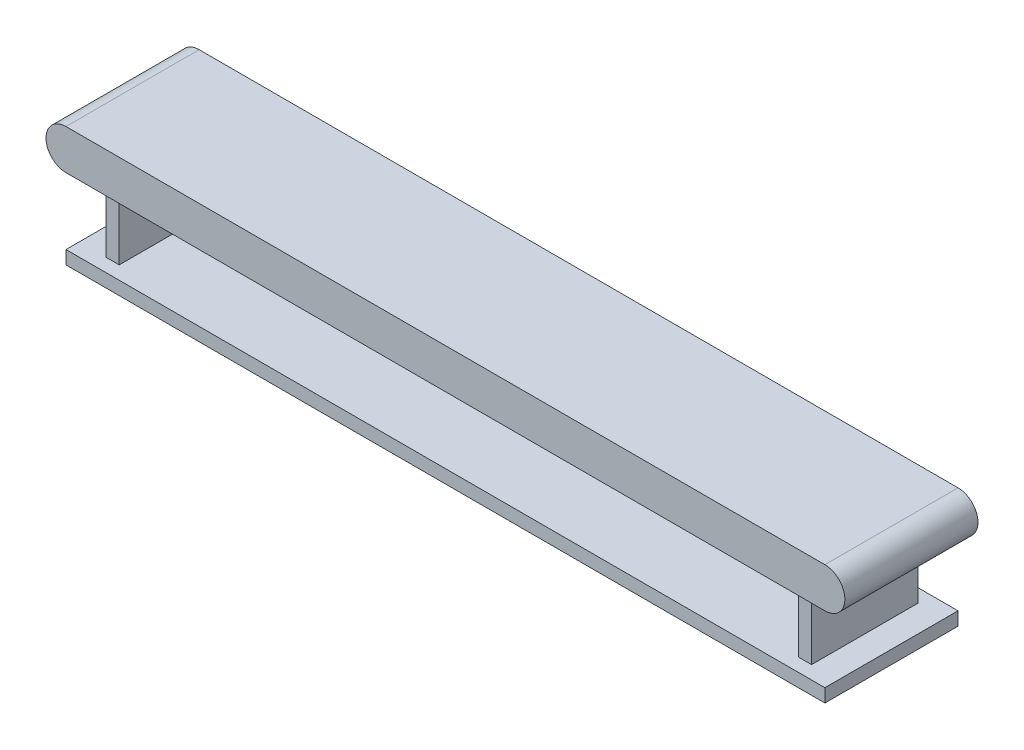
from build123d import *

# Parameters (mm, degrees)
SKETCH1_W           = 6000
SKETCH1_H           = 1000
BOSS_EXTRUDE1_DEPTH = 300
CUT_EXTRUDE1_DEPTH  = 1001
SKETCH5_W           = 100
SKETCH5_H           = 800
BOSS_EXTRUDE2_DEPTH = 500
SKETCH6_W           = 5700
SKETCH6_H           = 1000
BOSS_EXTRUDE3_DEPTH = 100


with BuildPart() as part:
    # Sketch1 → Boss-Extrude1 (new body)
    with BuildSketch(Plane(origin=(0, 0, 0), x_dir=(1, 0, 0), z_dir=(0, 1, 0))):
        Rectangle(SKETCH1_W, SKETCH1_H)
    extrude(amount=BOSS_EXTRUDE1_DEPTH)

    # Sketch4 → Cut-Extrude1 (cut, through all)
    with BuildSketch(Plane.XY.offset(500)):
        with BuildLine():
            Line((3000, 300), (2850, 300))
            ThreePointArc((2850, 300), (2956.066017178, 256.066017178), (3000, 150))
            Line((3000, 150), (3000, 300))
        make_face()
        with BuildLine():
            Line((3000, 0), (3000, 150))
            ThreePointArc((3000, 150), (2956.066017178, 43.933982822), (2850, 0))
            Line((2850, 0), (3000, 0))
        make_face()
        with BuildLine():
            Line((-2850, 300), (-3000, 300))
            Line((-3000, 300), (-3000, 150))
            ThreePointArc((-3000, 150), (-2956.066017178, 256.066017178), (-2850, 300))
        make_face()
        with BuildLine():
            ThreePointArc((-2850, 0), (-2956.066017178, 43.933982822), (-3000, 150))
            Line((-3000, 150), (-3000, 0))
            Line((-3000, 0), (-2850, 0))
        make_face()
    extrude(amount=-CUT_EXTRUDE1_DEPTH, mode=Mode.SUBTRACT)

    # Sketch5 → Boss-Extrude2 (add)
    with BuildSketch(Plane(origin=(0, 0, 0), x_dir=(-1, 0, 0), z_dir=(0, -1, 0))):
        with Locations((2600, 0)):
            Rectangle(SKETCH5_W, SKETCH5_H)
        with Locations((-2600, 0)):
            Rectangle(SKETCH5_W, SKETCH5_H)
    extrude(amount=BOSS_EXTRUDE2_DEPTH)

    # Sketch6 → Boss-Extrude3 (add)
    with BuildSketch(Plane(origin=(0, -500, 0), x_dir=(-1, 0, 0), z_dir=(0, -1, 0))):
        Rectangle(SKETCH6_W, SKETCH6_H)
    extrude(amount=BOSS_EXTRUDE3_DEPTH)


solid = part.part
